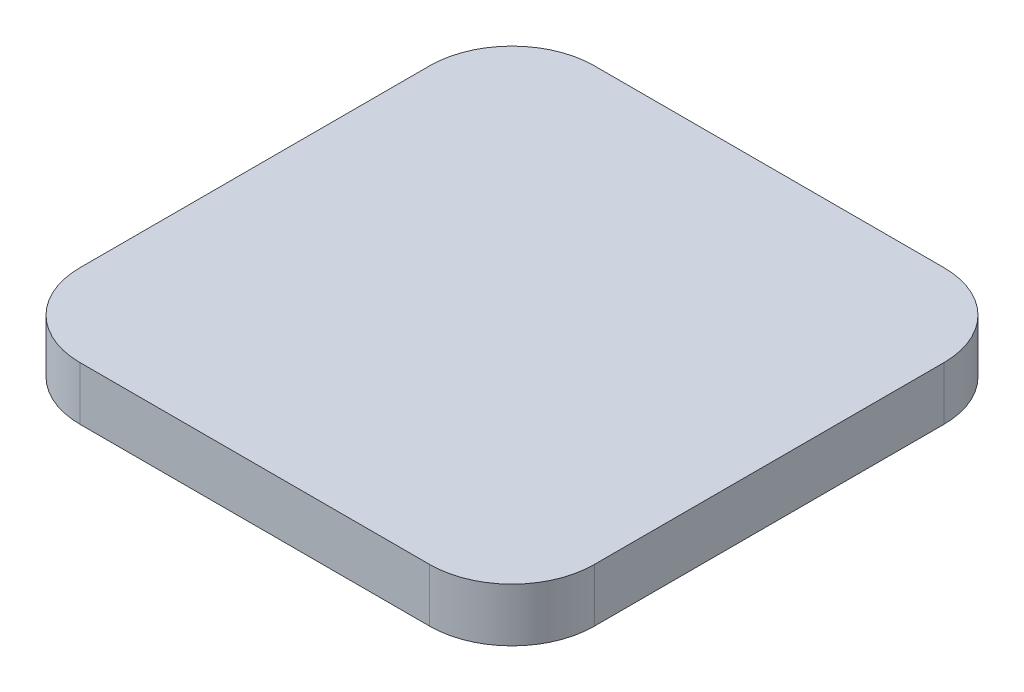
from build123d import *

# Parameters (mm, degrees)
SKETCH1_W           = 25
SKETCH1_H           = 25
BOSS_EXTRUDE1_DEPTH = 2.6
FILLET1_R           = 4
SKETCH2_R           = 0.4
BOSS_EXTRUDE2_DEPTH = 1.9


with BuildPart() as part:
    # Sketch1 → Boss-Extrude1 (new body)
    with BuildSketch(Plane(origin=(0, 0, 0), x_dir=(1, 0, 0), z_dir=(0, 1, 0))):
        Rectangle(SKETCH1_W, SKETCH1_H)
    extrude(amount=BOSS_EXTRUDE1_DEPTH)

    # Fillet1
    fillet1_edges = [part.edges().sort_by_distance(p)[0] for p in [
        (12.5, 1.3, 12.5),
        (-12.5, 1.3, 12.5),
        (-12.5, 1.3, -12.5),
        (12.5, 1.3, -12.5),
    ]]
    fillet(fillet1_edges, radius=FILLET1_R)

    # Sketch2 → Boss-Extrude2 (add)
    with BuildSketch(Plane.XZ):
        with Locations(Location((0, -2.5, 0), (0, 0, 270))):  # turned: the seam where the file's is
            Circle(SKETCH2_R)
    extrude(amount=BOSS_EXTRUDE2_DEPTH)


solid = part.part
